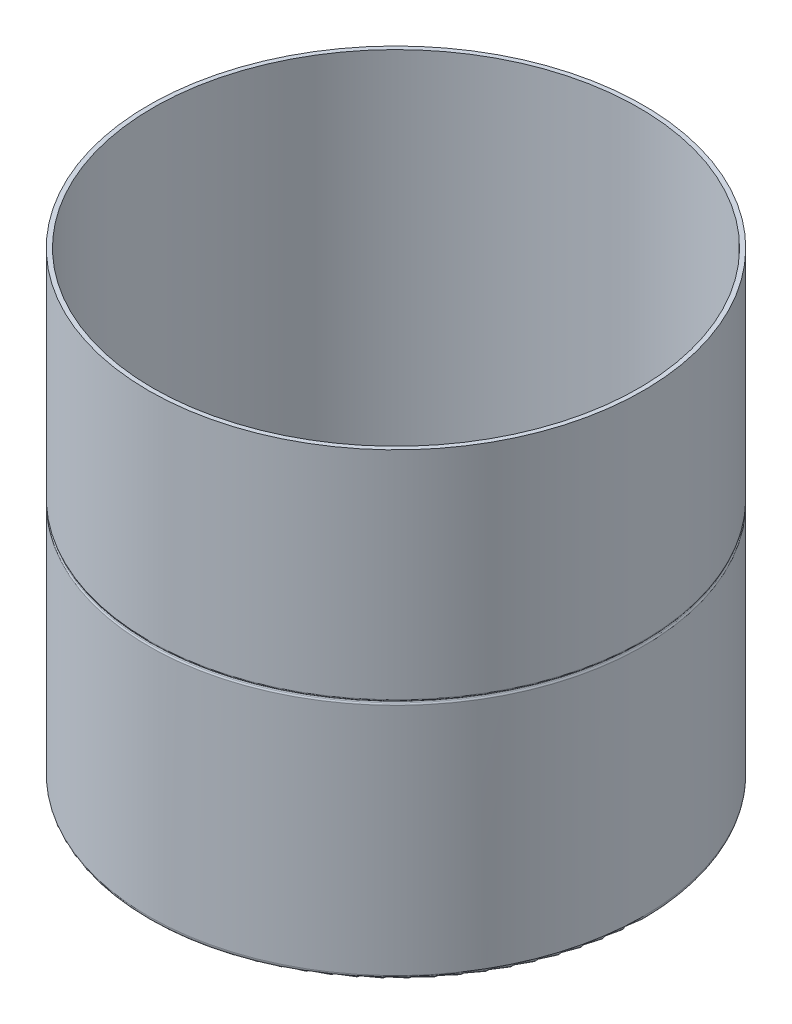
from build123d import *

# Parameters (mm, degrees)
SKETCH1_R           = 56.5
BOSS_EXTRUDE1_DEPTH = 105
SKETCH2_R           = 55.5
CUT_EXTRUDE1_DEPTH  = 100
SKETCH3_R           = 25
CUT_EXTRUDE2_DEPTH  = 5
SKETCH4_R           = 2.5
CUT_EXTRUDE3_DEPTH  = 5
SKETCH8_R           = 0.25
FILLET1_R           = 2
FILLET2_R           = 1
FILLET3_R           = 0.5
FILLET4_R           = 0.5


with BuildPart() as part:
    # Sketch1 → Boss-Extrude1 (new body)
    with BuildSketch(Plane(origin=(0, 0, 0), x_dir=(1, 0, 0), z_dir=(0, 1, 0))):
        with Locations(Location((0, 0, 0), (0, 0, 270))):
            Circle(SKETCH1_R)
    extrude(amount=BOSS_EXTRUDE1_DEPTH)

    # Sketch2 → Cut-Extrude1 (cut)
    with BuildSketch(Plane(origin=(0, 105, 0), x_dir=(1, 0, 0), z_dir=(0, 1, 0))):
        with Locations(Location((0, 0, 0), (0, 0, 270))):
            Circle(SKETCH2_R)
    extrude(amount=-CUT_EXTRUDE1_DEPTH, mode=Mode.SUBTRACT)

    # Sketch3 → Cut-Extrude2 (cut)
    with BuildSketch(Plane.XZ):
        with Locations(Location((0, 0, 0), (0, 0, 270))):
            Circle(SKETCH3_R)
    extrude(amount=-CUT_EXTRUDE2_DEPTH, mode=Mode.SUBTRACT)

    # Sketch4 → Cut-Extrude3 (cut)
    with BuildSketch(Plane.XZ):
        with Locations(Location((44, 0, 0), (0, 0, 270))):
            Circle(SKETCH4_R)
        with Locations(Location((-44, 0, 0), (0, 0, 270))):
            Circle(SKETCH4_R)
    extrude(amount=-CUT_EXTRUDE3_DEPTH, mode=Mode.SUBTRACT)

    # Sketch8 → Cut-Revolve2 (revolve, cut)
    with BuildSketch(Plane(origin=(0, 0, 0), x_dir=(0, 0, -1), z_dir=(1, 0, 0)), mode=Mode.PRIVATE) as cut_revolve2_sk:
        with Locations((56.5, 55)):
            Circle(SKETCH8_R)
    revolve(cut_revolve2_sk.sketch.rotate(Axis((0, 105, 0), (0, -1, 0)), 180), axis=Axis((0, 105, 0), (0, -1, 0)), mode=Mode.SUBTRACT)

    # Fillet1
    fillet1_edges = [part.edges().sort_by_distance(p)[0] for p in [
        (0, 0, 25),
    ]]
    fillet(fillet1_edges, radius=FILLET1_R)

    # Fillet2
    fillet2_edges = [part.edges().sort_by_distance(p)[0] for p in [
        (0, 0, -56.5),
    ]]
    fillet(fillet2_edges, radius=FILLET2_R)

    # Fillet3
    fillet3_edges = [part.edges().sort_by_distance(p)[0] for p in [
        (0, 54.75, -56.5),
    ]]
    fillet(fillet3_edges, radius=FILLET3_R)

    # Fillet4
    fillet4_edges = [part.edges().sort_by_distance(p)[0] for p in [
        (0, 55.25, -56.5),
    ]]
    fillet(fillet4_edges, radius=FILLET4_R)


solid = part.part
